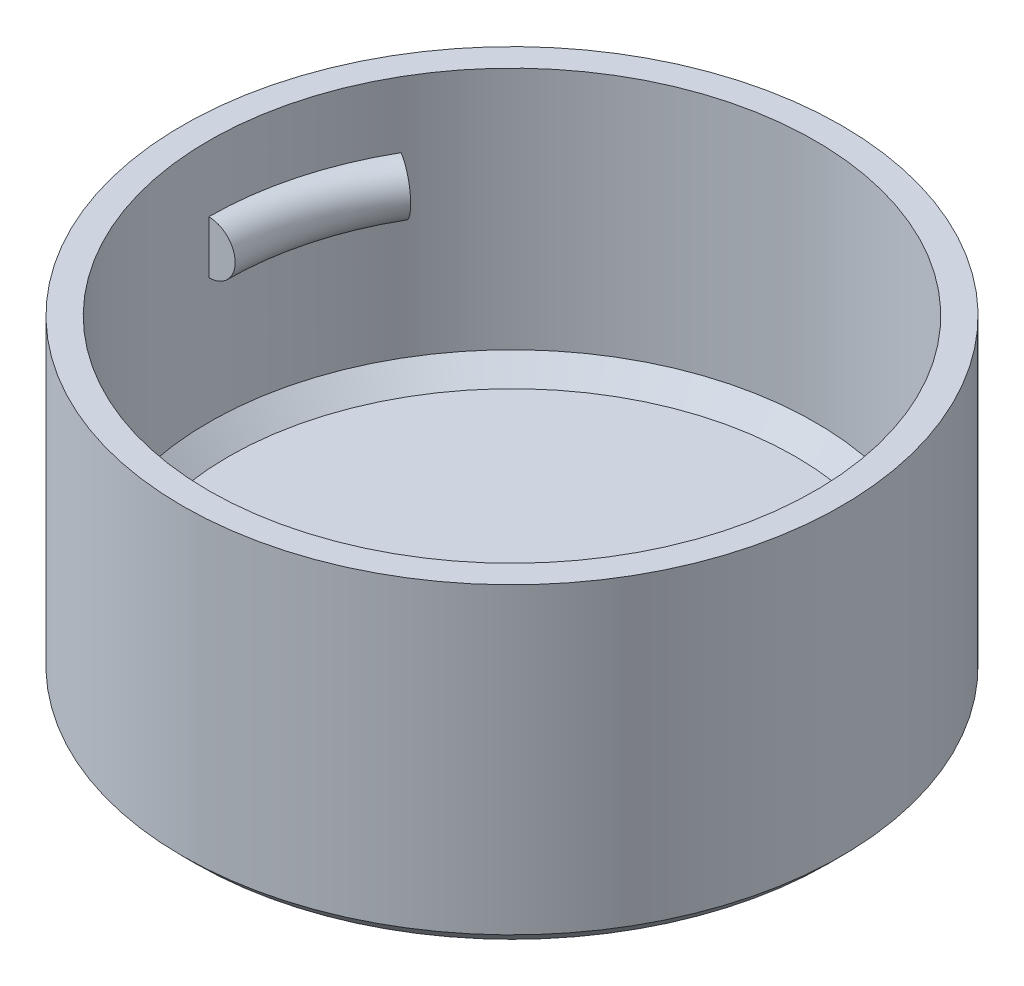
from build123d import *

# Parameters (mm, degrees)
SKETCH1_R           = 12.5
BOSS_EXTRUDE2_DEPTH = 2
SKETCH2_R           = 12.5
SKETCH2_R_2         = 11.5
BOSS_EXTRUDE3_DEPTH = 10
REVOLVE1_ANGLE      = 30
CHAMFER1_SIZE       = 0.5
CHAMFER2_SIZE       = 0.75


with BuildPart() as part:
    # Sketch1 → Boss-Extrude2 (new body)
    with BuildSketch(Plane(origin=(0, 0, 0), x_dir=(1, 0, 0), z_dir=(0, 1, 0))):
        with Locations(Location((0, 0, 0), (0, 0, 270))):
            Circle(SKETCH1_R)
    extrude(amount=BOSS_EXTRUDE2_DEPTH)

    # Sketch2 → Boss-Extrude3 (add)
    with BuildSketch(Plane(origin=(0, 2, 0), x_dir=(1, 0, 0), z_dir=(0, 1, 0))):
        with Locations(Location((0, 0, 0), (0, 0, 270))):
            Circle(SKETCH2_R)
        with Locations(Location((0, 0, 0), (0, 0, 270))):
            Circle(SKETCH2_R_2, mode=Mode.SUBTRACT)
    extrude(amount=BOSS_EXTRUDE3_DEPTH)

    # Sketch3 → Revolve1 (revolve)
    with BuildSketch(Plane.XY):
        with BuildLine():
            Line((-11.5, 9.5), (-11.5, 7.5))
            ThreePointArc((-11.5, 7.5), (-10.5, 8.5), (-11.5, 9.5))
        make_face()
        with BuildLine():
            Line((11.5, 9.5), (11.5, 7.5))
            ThreePointArc((11.5, 7.5), (10.5, 8.5), (11.5, 9.5))
        make_face()
    revolve(axis=Axis((0, 19.49850662, 0), (0, -1, 0)), revolution_arc=REVOLVE1_ANGLE)

    # Chamfer1
    chamfer1_edges = [part.edges().sort_by_distance(p)[0] for p in [
        (0, 0, -12.5),
    ]]
    chamfer(chamfer1_edges, length=CHAMFER1_SIZE)

    # Chamfer2
    chamfer2_edges = [part.edges().sort_by_distance(p)[0] for p in [
        (0, 2, -11.5),
    ]]
    chamfer(chamfer2_edges, length=CHAMFER2_SIZE)


solid = part.part
